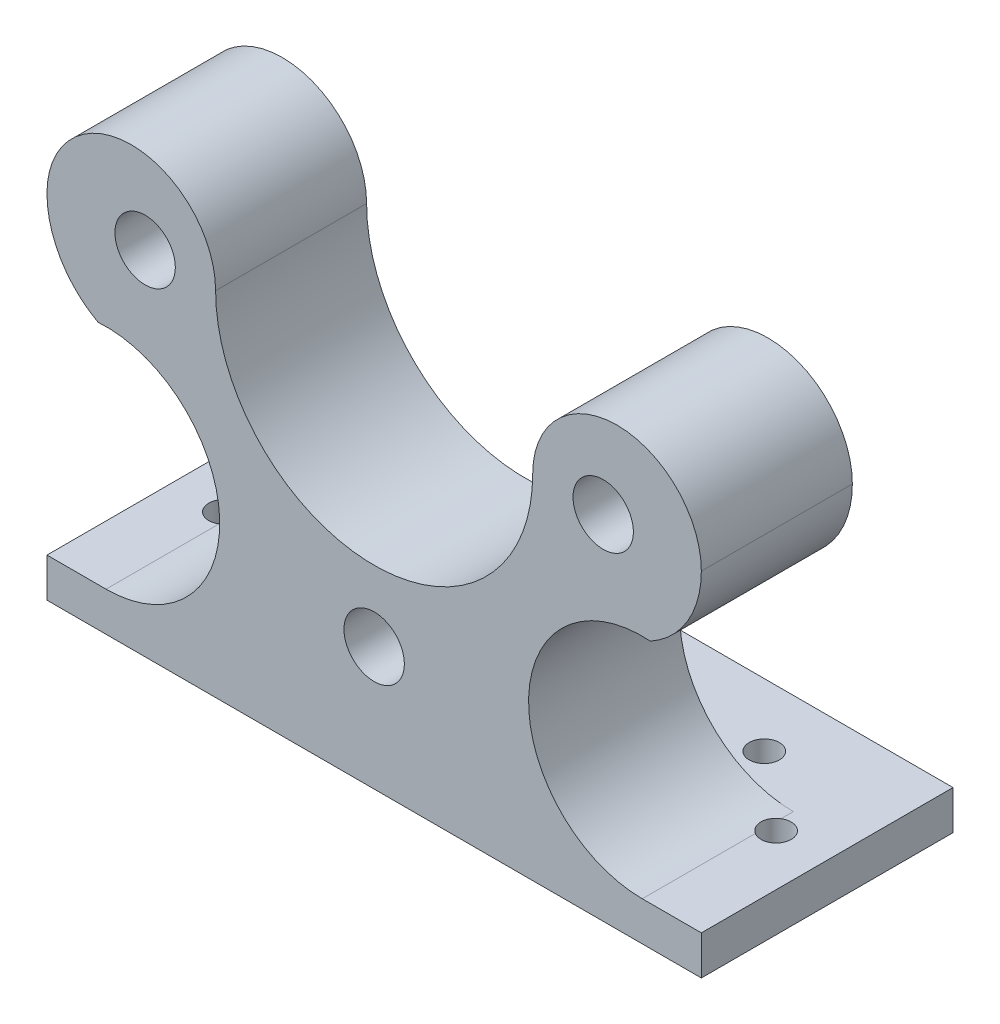
from build123d import *

# Parameters (mm, degrees)
SKETCH_1_W               = 65
SKETCH_1_H               = 70
EXTRUDE_1_DEPTH          = 25
SKETCH_2_R               = 15.75
CUT_EXTRUDE_1_DEPTH      = 97.945264261
SKETCH_4_R               = 3
CUT_EXTRUDE_2_DEPTH      = 40
PATTERN_CIRCULAR_1_COUNT = 4
CUT_EXTRUDE_3_DEPTH      = 97.945264261
CUT_EXTRUDE_START        = -77.329829847
CUT_EXTRUDE_5_DEPTH      = 97.329829847
SKETCH_8_R               = 1.25
SKETCH_8_R_2             = 1.5
CUT_EXTRUDE_6_DEPTH      = 10
SKETCH_9_W               = 81.802440552
SKETCH_9_H               = 62.233215756
CUT_EXTRUDE_7_DEPTH      = 10


with BuildPart() as part:
    # 草图1 → 凸台-拉伸1 (new body)
    with BuildSketch(Plane.XY):
        with Locations((-15.56280925, 45.394966444)):
            Rectangle(SKETCH_1_W, SKETCH_1_H)
    extrude(amount=EXTRUDE_1_DEPTH)

    # 草图2 → 切除-拉伸1 (cut, through all)
    with BuildSketch(Plane.XY.offset(25)):
        with Locations((-15.56280925, 45.394966444)):
            Circle(SKETCH_2_R)
    extrude(amount=-CUT_EXTRUDE_1_DEPTH, mode=Mode.SUBTRACT)

    # 草图4 → 切除-拉伸2 (cut)
    with BuildSketch(Plane(origin=(0, 0, 0), x_dir=(-1, 0, 0), z_dir=(0, 0, -1))):
        with Locations((-7.18719075, 45.394966444)):
            Circle(SKETCH_4_R)
    cut_extrude_2 = extrude(amount=-CUT_EXTRUDE_2_DEPTH, mode=Mode.SUBTRACT)

    # 阵列(圆周)1: 切除-拉伸2 ×4 about axis
    pattern_circular_1_axis = Axis((-15.56280925, 45.394966444, 0), (0, 0, 1))
    for i in range(1, PATTERN_CIRCULAR_1_COUNT):
        add(cut_extrude_2.rotate(pattern_circular_1_axis, i * 360 / PATTERN_CIRCULAR_1_COUNT), mode=Mode.SUBTRACT)

    # 草图6 → 切除-拉伸3 (cut, through all)
    with BuildSketch(Plane.XY.offset(25)):
        with BuildLine():
            Line((-31.31280925, 45.394966444), (0.18719075, 45.394966444))
            ThreePointArc((0.18719075, 45.394966444), (8.56219075, 53.769966444), (16.93719075, 45.394966444))
            Line((16.93719075, 45.394966444), (16.93719075, 80.394966444))
            Line((16.93719075, 80.394966444), (-48.06280925, 80.394966444))
            Line((-48.06280925, 80.394966444), (-48.06280925, 45.394966444))
            ThreePointArc((-48.06280925, 45.394966444), (-39.68780925, 53.769966444), (-31.31280925, 45.394966444))
        make_face()
    extrude(amount=-CUT_EXTRUDE_3_DEPTH, mode=Mode.SUBTRACT)

    # 草图7 → 切除-拉伸5 (cut)
    with BuildSketch(Plane.XY.offset(25).offset(CUT_EXTRUDE_START)):
        with BuildLine():
            Line((-48.06280925, 45.394966444), (-48.06280925, 14.278358566))
            Line((-48.06280925, 14.278358566), (-42.197147473, 14.278358566))
            ThreePointArc((-42.197147473, 14.278358566), (-30.908342931, 25.972564608), (-42.993400823, 36.841922394))
            ThreePointArc((-42.993400823, 36.841922394), (-46.700248306, 40.423712469), (-48.06280925, 45.394966444))
        make_face()
    cut_extrude_5 = extrude(amount=CUT_EXTRUDE_5_DEPTH, mode=Mode.SUBTRACT)

    # 镜向1: 切除-拉伸5 across plane
    add(cut_extrude_5.mirror(Plane.ZY.offset(15.56280925)), mode=Mode.SUBTRACT)

    # 草图8 → 切除-拉伸6 (cut)
    with BuildSketch(Plane.XZ.offset(-10.394966444)):
        with Locations((-28.06280925, 12.5)):
            Circle(SKETCH_8_R)
        with Locations((-42.993400823, 12.5)):
            Circle(SKETCH_8_R_2)
        with Locations((-35.56280925, 6.25)):
            Circle(SKETCH_8_R_2)
    cut_extrude_6 = extrude(amount=-CUT_EXTRUDE_6_DEPTH, mode=Mode.SUBTRACT)

    # 镜向2: 切除-拉伸6 across plane
    add(cut_extrude_6.mirror(Plane.ZY.offset(15.56280925)), mode=Mode.SUBTRACT)

    # 草图9 → 切除-拉伸7 (cut)
    with BuildSketch(Plane(origin=(0, 0, 0), x_dir=(-1, 0, 0), z_dir=(0, 0, -1))):
        with Locations((15.56280925, 45.394966444)):
            Rectangle(SKETCH_9_W, SKETCH_9_H)
    extrude(amount=-CUT_EXTRUDE_7_DEPTH, mode=Mode.SUBTRACT)


solid = part.part
